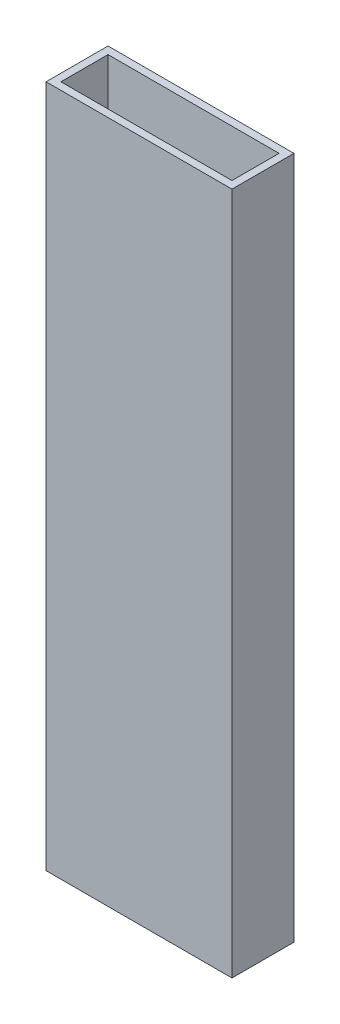
from build123d import *

# Parameters (mm, degrees)
SKETCH1_W           = 76.2
SKETCH1_H           = 25.4
SKETCH1_W_2         = 70.104
SKETCH1_H_2         = 19.304
BOSS_EXTRUDE1_DEPTH = 305.4
CUT_EXTRUDE1_START  = -12.7
SKETCH3_W           = 76.2
SKETCH3_H           = 25.4
CUT_EXTRUDE1_DEPTH  = 25.4
CUT_EXTRUDE2_START  = -12.7
SKETCH4_W           = 76.2
SKETCH4_H           = 25.4
CUT_EXTRUDE2_DEPTH  = 25.4


with BuildPart() as part:
    # Sketch1 → Boss-Extrude1 (new body)
    with BuildSketch(Plane(origin=(0, 0, 0), x_dir=(1, 0, 0), z_dir=(0, 1, 0))):
        Rectangle(SKETCH1_W, SKETCH1_H)
        Rectangle(SKETCH1_W_2, SKETCH1_H_2, mode=Mode.SUBTRACT)
    extrude(amount=BOSS_EXTRUDE1_DEPTH)

    # Sketch3 → Cut-Extrude1 (cut)
    with BuildSketch(Plane(origin=(0, 305.4, 0), x_dir=(-1, 0, 0), z_dir=(0, 0, -1)).offset(CUT_EXTRUDE1_START)):
        Rectangle(SKETCH3_W, SKETCH3_H)
    extrude(amount=CUT_EXTRUDE1_DEPTH, mode=Mode.SUBTRACT)

    # Sketch4 → Cut-Extrude2 (cut)
    with BuildSketch(Plane(origin=(0, 0, 0), x_dir=(-1, 0, 0), z_dir=(0, 0, -1)).offset(CUT_EXTRUDE2_START)):
        Rectangle(SKETCH4_W, SKETCH4_H)
    extrude(amount=CUT_EXTRUDE2_DEPTH, mode=Mode.SUBTRACT)


solid = part.part
